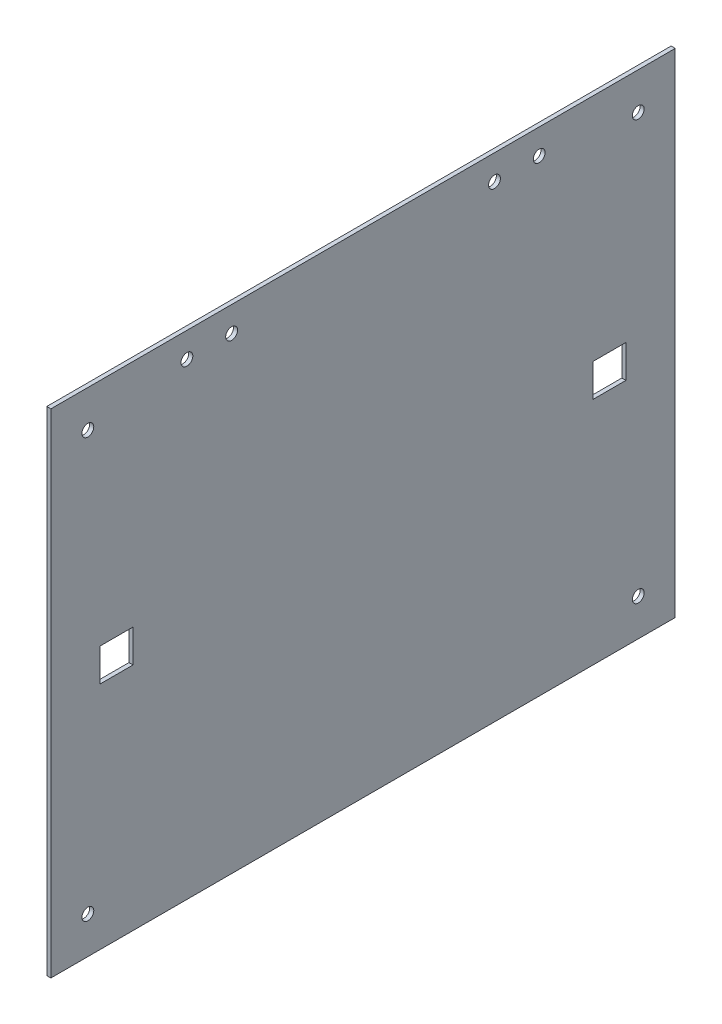
from build123d import *

# Parameters (mm, degrees)
SKETCH1_W           = 241.3
SKETCH1_H           = 190.5
BOSS_EXTRUDE1_DEPTH = 1.5875
SKETCH2_R           = 2.286
CUT_EXTRUDE1_DEPTH  = 2.5875
SKETCH3_R           = 2.286
CUT_EXTRUDE2_DEPTH  = 2.5875
SKETCH4_W           = 12.7
SKETCH4_H           = 12.7
CUT_EXTRUDE3_DEPTH  = 2.5875


with BuildPart() as part:
    # Sketch1 → Boss-Extrude1 (new body)
    with BuildSketch(Plane(origin=(0, 0, 0), x_dir=(0, 0, -1), z_dir=(1, 0, 0))):
        with Locations((120.65, 95.25)):
            Rectangle(SKETCH1_W, SKETCH1_H)
    extrude(amount=BOSS_EXTRUDE1_DEPTH)

    # Sketch2 → Cut-Extrude1 (cut, through all)
    with BuildSketch(Plane(origin=(1.5875, 0, 0), x_dir=(0, 0, -1), z_dir=(1, 0, 0))):
        with Locations((227.0125, 14.2875)):
            Circle(SKETCH2_R)
        with Locations((227.0125, 176.2125)):
            Circle(SKETCH2_R)
        with Locations((14.2875, 14.2875)):
            Circle(SKETCH2_R)
        with Locations((14.2875, 176.2125)):
            Circle(SKETCH2_R)
    extrude(amount=-CUT_EXTRUDE1_DEPTH, mode=Mode.SUBTRACT)

    # Sketch3 → Cut-Extrude2 (cut, through all)
    with BuildSketch(Plane(origin=(1.5875, 0, 0), x_dir=(0, 0, -1), z_dir=(1, 0, 0))):
        with Locations((52.578, 180.7845)):
            Circle(SKETCH3_R)
        with Locations((69.85, 180.7845)):
            Circle(SKETCH3_R)
        with Locations((171.45, 180.7845)):
            Circle(SKETCH3_R)
        with Locations((188.722, 180.7845)):
            Circle(SKETCH3_R)
    extrude(amount=-CUT_EXTRUDE2_DEPTH, mode=Mode.SUBTRACT)

    # Sketch4 → Cut-Extrude3 (cut, through all)
    with BuildSketch(Plane(origin=(1.5875, 0, 0), x_dir=(0, 0, -1), z_dir=(1, 0, 0))):
        with Locations((25.4, 95.25)):
            Rectangle(SKETCH4_W, SKETCH4_H)
        with Locations((215.9, 95.25)):
            Rectangle(SKETCH4_W, SKETCH4_H)
    extrude(amount=-CUT_EXTRUDE3_DEPTH, mode=Mode.SUBTRACT)


solid = part.part
